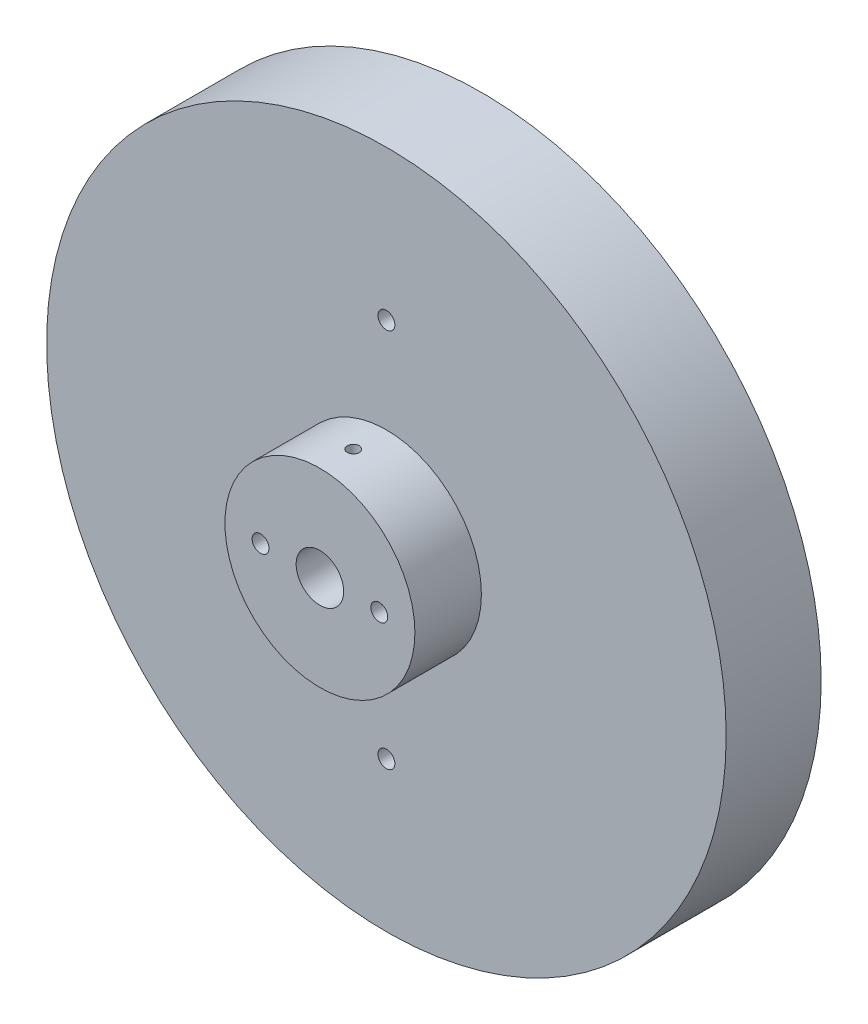
from build123d import *

# Parameters (mm, degrees)
SKETCH2_R               = 45.4279
BOSS_EXTRUDE1_DEPTH     = 12.7
SKETCH3_R               = 12.7
BOSS_EXTRUDE2_DEPTH     = 8.89
SKETCH4_R               = 3.175
SKETCH4_R_2             = 1.1303
CUT_EXTRUDE1_DEPTH      = 22.59
SKETCH5_R               = 0.79375
CUT_EXTRUDE2_DEPTH      = 46.4279
CUT_EXTRUDE2_DEPTH_BACK = 46.4279
SKETCH6_R               = 1.1303
CUT_EXTRUDE3_DEPTH      = 13.7000001


with BuildPart() as part:
    # Sketch2 → Boss-Extrude1 (new body)
    with BuildSketch(Plane.XY):
        Circle(SKETCH2_R)
    extrude(amount=BOSS_EXTRUDE1_DEPTH)

    # Sketch3 → Boss-Extrude2 (add)
    with BuildSketch(Plane.XY.offset(12.7)):
        Circle(SKETCH3_R)
    extrude(amount=BOSS_EXTRUDE2_DEPTH)

    # Sketch4 → Cut-Extrude1 (cut, through all)
    with BuildSketch(Plane.XY.offset(21.59)):
        Circle(SKETCH4_R)
        with Locations((-7.9375, 0)):
            Circle(SKETCH4_R_2)
        with Locations((7.9375, 0)):
            Circle(SKETCH4_R_2)
    extrude(amount=-CUT_EXTRUDE1_DEPTH, mode=Mode.SUBTRACT)

    # Sketch5 → Cut-Extrude2 (cut, two sides)
    with BuildSketch(Plane(origin=(0, 0, 0), x_dir=(1, 0, 0), z_dir=(0, 1, 0))) as cut_extrude2_sk:
        with Locations((0, -17.145)):
            Circle(SKETCH5_R)
    extrude(amount=CUT_EXTRUDE2_DEPTH, mode=Mode.SUBTRACT)
    extrude(cut_extrude2_sk.sketch, amount=-CUT_EXTRUDE2_DEPTH_BACK, mode=Mode.SUBTRACT)

    # Sketch6 → Cut-Extrude3 (cut, through all)
    with BuildSketch(Plane.XY.offset(12.7)):
        with Locations((0, 25.4)):
            Circle(SKETCH6_R)
        with Locations((0, -25.4)):
            Circle(SKETCH6_R)
    extrude(amount=-CUT_EXTRUDE3_DEPTH, mode=Mode.SUBTRACT)


solid = part.part
